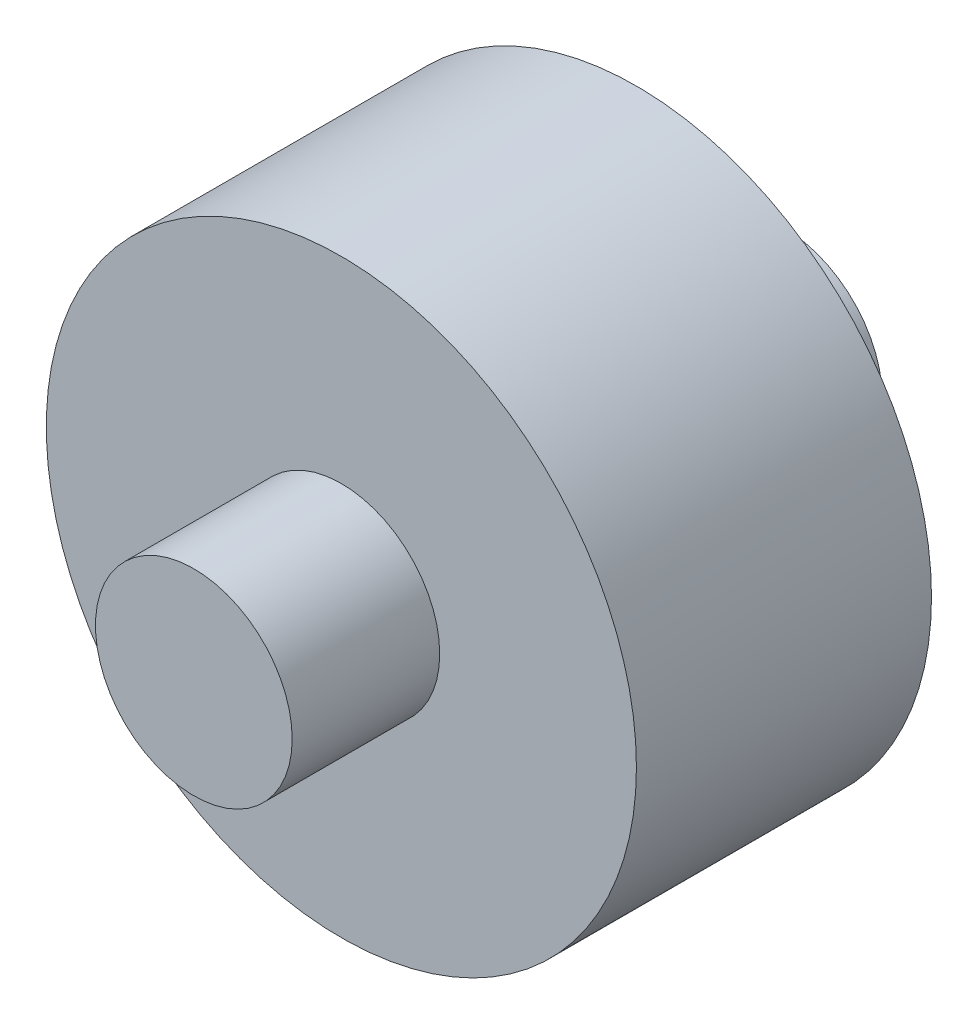
from build123d import *

# Parameters (mm, degrees)
SKETCH1_R           = 9.525
BOSS_EXTRUDE1_DEPTH = 4.7625
SKETCH2_R           = 3.175
BOSS_EXTRUDE2_DEPTH = 9.525
SKETCH3_R           = 3.175
CUT_EXTRUDE1_DEPTH  = 10.525


with BuildPart() as part:
    # Sketch1 → Boss-Extrude1 (new body, symmetric)
    with BuildSketch(Plane.XY):
        Circle(SKETCH1_R)
    extrude(amount=BOSS_EXTRUDE1_DEPTH, both=True)

    # Sketch2 → Boss-Extrude2 (add, symmetric)
    with BuildSketch(Plane.XY):
        Circle(SKETCH2_R)
    extrude(amount=BOSS_EXTRUDE2_DEPTH, both=True)

    # Sketch3 → Cut-Extrude1 (cut, through all)
    with BuildSketch(Plane(origin=(0, 0, 0), x_dir=(0, 0, -1), z_dir=(1, 0, 0))):
        Circle(SKETCH3_R)
    extrude(amount=-CUT_EXTRUDE1_DEPTH, mode=Mode.SUBTRACT)


solid = part.part
